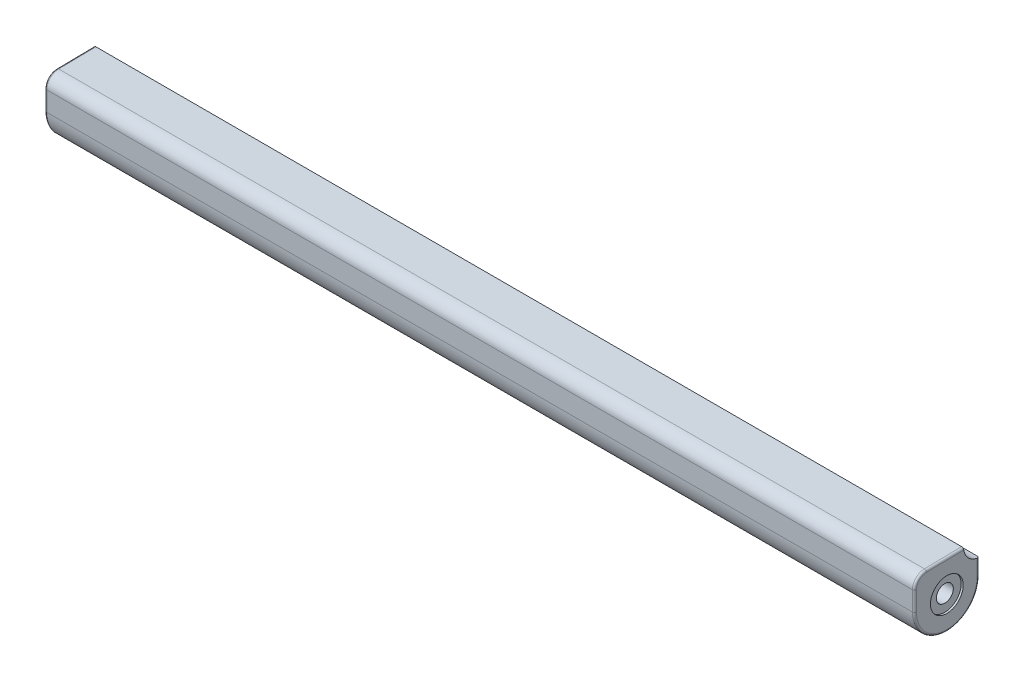
from build123d import *

# Parameters (mm, degrees)
SKETCH1_R           = 2.1
BOSS_EXTRUDE1_DEPTH = 215
FILLET1_R           = 0.5
CUT_EXTRUDE6_DEPTH  = 3.5
SKETCH11_R          = 4.05
CUT_EXTRUDE7_DEPTH  = 0.5
CUT_EXTRUDE8_DEPTH  = 216.297468637


with BuildPart() as part:
    # Sketch1 → Boss-Extrude1 (new body)
    with BuildSketch(Plane(origin=(0, 0, 0), x_dir=(0, 0, -1), z_dir=(1, 0, 0))):
        with BuildLine():
            ThreePointArc((-8, 0), (0, -8), (8, 0))
            Line((8, 0), (8, 4.953035538))
            ThreePointArc((8, 4.953035538), (7.10478138, 7.090766893), (4.953403104, 7.952673638))
            Line((4.953403104, 7.952673638), (-5.046596896, 7.797331911))
            ThreePointArc((-5.046596896, 7.797331911), (-7.137731355, 6.902475191), (-8, 4.797693812))
            Line((-8, 4.797693812), (-8, 0))
        make_face()
        Circle(SKETCH1_R, mode=Mode.SUBTRACT)
    extrude(amount=BOSS_EXTRUDE1_DEPTH)

    # Fillet1
    fillet1_edges = [part.edges().sort_by_distance(p)[0] for p in [
        (215, 6.902475191, 7.137731355),
        (215, 7.875002775, 0.046596896),
        (215, 7.090766893, -7.10478138),
        (215, 2.476517769, -8),
        (215, -8, 0),
        (0, 7.090766893, -7.10478138),
        (0, 2.476517769, -8),
        (0, -8, 0),
        (0, 2.398846906, 8),
        (0, 6.902475191, 7.137731355),
        (215, 2.398846906, 8),
        (0, 7.875002775, 0.046596896),
    ]]
    fillet(fillet1_edges, radius=FILLET1_R)

    # Sketch8 → Cut-Extrude6 (cut)
    with BuildSketch(Plane(origin=(209, 0, 0), x_dir=(0, 0, -1), z_dir=(1, 0, 0))):
        Polygon((2.040874515, 3.555019627), (10.204569272, 3.555019627), (10.291698633, -3.544958989), (2.058300051, -3.544958989), (-2.040874515, -3.555019627), (-4.099174565, -0.010060638), (-2.058300051, 3.544958989), align=None)
    cut_extrude6 = extrude(amount=-CUT_EXTRUDE6_DEPTH, mode=Mode.SUBTRACT)

    # Sketch11 → Cut-Extrude7 (cut)
    with BuildSketch(Plane(origin=(215, 0, 0), x_dir=(0, 0, -1), z_dir=(1, 0, 0))):
        Circle(SKETCH11_R)
    cut_extrude7 = extrude(amount=-CUT_EXTRUDE7_DEPTH, mode=Mode.SUBTRACT)

    # Mirror1: Cut-Extrude6, Cut-Extrude7 across plane
    add(cut_extrude6.mirror(Plane.ZY.offset(-107.5)), mode=Mode.SUBTRACT)
    add(cut_extrude7.mirror(Plane.ZY.offset(-107.5)), mode=Mode.SUBTRACT)

    # Sketch13 → Cut-Extrude8 (cut, through all)
    with BuildSketch(Plane.ZY):
        with BuildLine():
            Line((-8.155806574, 4), (-8.155806574, 8.298439356))
            Line((-8.155806574, 8.298439356), (-4.156962159, 8.096142326))
            ThreePointArc((-4.156962159, 8.096142326), (-5.293589836, 5.205771064), (-8.155806574, 4))
        make_face()
    extrude(amount=-CUT_EXTRUDE8_DEPTH, mode=Mode.SUBTRACT)


solid = part.part
